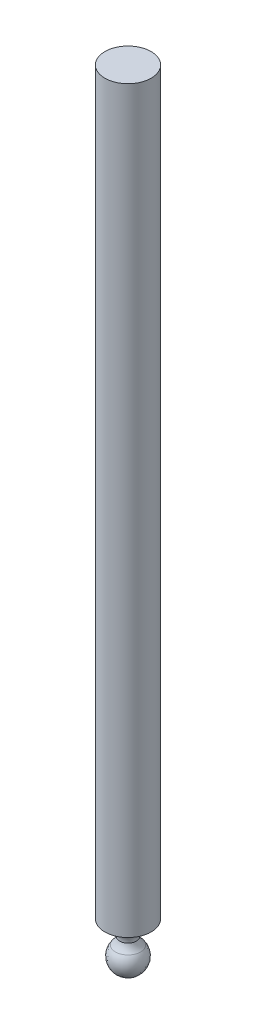
from build123d import *

# Parameters (mm, degrees)
SKETCH_4_R      = 7.5
EXTRUDE_1_DEPTH = 240


with BuildPart() as part:
    # Эскиз3 → Повернуть1 (revolve)
    with BuildSketch(Plane(origin=(0, 0, 0), x_dir=(0, 0, -1), z_dir=(1, 0, 0))):
        with BuildLine():
            Line((-7.5, 0), (0, 0))
            Line((0, 0), (0, -15.446893791))
            ThreePointArc((0, -15.446893791), (-4.626825218, -12.686050609), (-4.06104556, -7.327911002))
            ThreePointArc((-4.06104556, -7.327911002), (-3.215408683, -6.250742146), (-2.689353951, -4.986360522))
            ThreePointArc((-2.689353951, -4.986360522), (-4.103216638, -1.536658017), (-7.5, 0))
        make_face()
    revolve(axis=Axis((0, 11.108011972, 0), (0, -1, 0)))

    # Эскиз4 → Бобышка-Вытянуть1 (add)
    with BuildSketch(Plane(origin=(0, 0, 0), x_dir=(1, 0, 0), z_dir=(0, 1, 0))):
        Circle(SKETCH_4_R)
    extrude(amount=EXTRUDE_1_DEPTH)


solid = part.part
